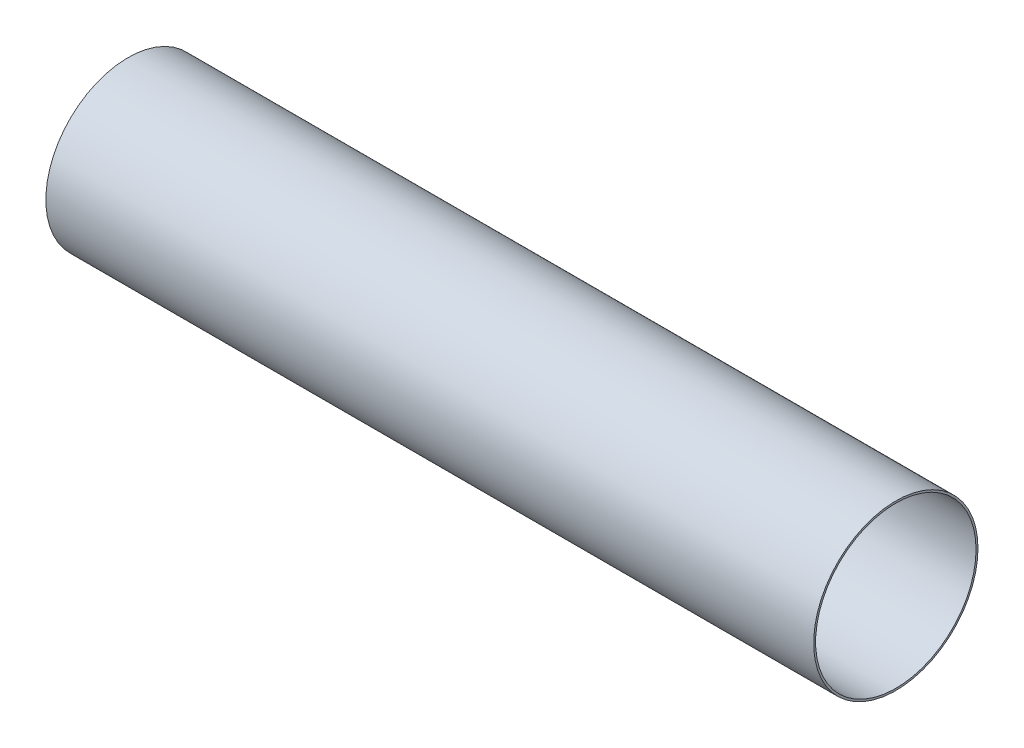
from build123d import *

# Parameters (mm, degrees)
SKETCH1_R           = 84.55
BOSS_EXTRUDE2_DEPTH = 790
SKETCH3_R           = 82.55
CUT_EXTRUDE1_DEPTH  = 940


with BuildPart() as part:
    # Sketch1 → Boss-Extrude2 (new body)
    with BuildSketch(Plane(origin=(0, 0, 0), x_dir=(0, 0, -1), z_dir=(1, 0, 0))):
        Circle(SKETCH1_R)
    extrude(amount=BOSS_EXTRUDE2_DEPTH)

    # Sketch3 → Cut-Extrude1 (cut)
    with BuildSketch(Plane(origin=(790, 0, 0), x_dir=(0, 0, -1), z_dir=(1, 0, 0))):
        Circle(SKETCH3_R)
    extrude(amount=-CUT_EXTRUDE1_DEPTH, mode=Mode.SUBTRACT)


solid = part.part
